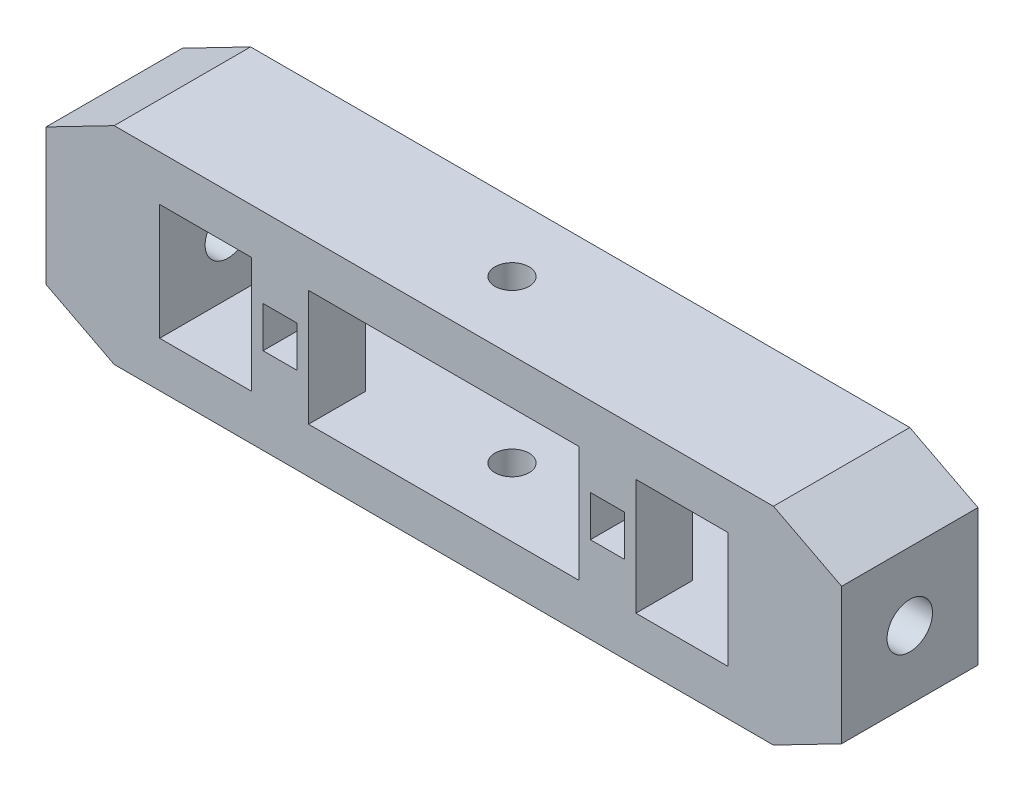
from build123d import *

# Parameters (mm, degrees)
SKETCH1_W                  = 25
SKETCH1_H                  = 6
SKETCH1_R                  = 0.75
BASEFRAME_DEPTH            = 2
SKETCH2_W                  = 29
SKETCH2_H                  = 6
SKETCH2_R                  = 0.75
BOSS_EXTRUDE2_DEPTH        = 2
SKETCH2_3_W                = 2
SKETCH2_3_H                = 6
BOSS_EXTRUDE3_DEPTH        = 7.1
BOSS_EXTRUDE4_DEPTH        = 6
SKETCH4_R                  = 1
SHAFTHOLE_DEPTH            = 36
SLOTBLOCK_START            = -7.1
SKETCH5_W                  = 2.5
SKETCH5_H                  = 2.5
SLOTBLOCK_DEPTH            = 5.1
SKETCH6_W                  = 0.9
SKETCH6_H                  = 0.9
SKETCH6_W_2                = 1.5
SKETCH6_H_2                = 1.5
CLIPENTRANCE_DEPTH         = 2
SKETCH6_3_W                = 0.9
SKETCH6_3_H                = 0.9
CABLEEXIT_DEPTH            = 7
SKETCH7_W                  = 1.5
SKETCH7_H                  = 1.5
CLIPLOCKSLOT_DEPTH         = 0.6
SKETCH8_W                  = 1.5
SKETCH8_H                  = 0.3
CLIPLOCKCLEARANCECUT_DEPTH = 0.5


with BuildPart() as part:
    # Sketch1 → BaseFrame (new body)
    with BuildSketch(Plane(origin=(0, 0, 0), x_dir=(1, 0, 0), z_dir=(0, 1, 0))):
        Rectangle(SKETCH1_W, SKETCH1_H)
        Circle(SKETCH1_R, mode=Mode.SUBTRACT)
    extrude(amount=BASEFRAME_DEPTH)



with BuildPart() as body_2:
    # Sketch2 → Boss-Extrude2 (new body)
    with BuildSketch(Plane(origin=(0, 7.1, 0), x_dir=(1, 0, 0), z_dir=(0, 1, 0))):
        Rectangle(SKETCH2_W, SKETCH2_H)
        Circle(SKETCH2_R, mode=Mode.SUBTRACT)
    extrude(amount=BOSS_EXTRUDE2_DEPTH)


with BuildPart() as part_1:
    add(part.part)

    add(body_2.part)  # Boss-Extrude3 merges body 2
    # Sketch2_3 → Boss-Extrude3 (add)
    with BuildSketch(Plane(origin=(0, 7.1, 0), x_dir=(1, 0, 0), z_dir=(0, 1, 0))):
        with Locations((-13.5, 0)):
            Rectangle(SKETCH2_3_W, SKETCH2_3_H)
        with Locations((13.5, 0)):
            Rectangle(SKETCH2_3_W, SKETCH2_3_H)
    extrude(amount=-BOSS_EXTRUDE3_DEPTH)

    # Sketch3 → Boss-Extrude4 (add)
    with BuildSketch(Plane(origin=(0, 0, -3), x_dir=(-1, 0, 0), z_dir=(0, 0, -1))):
        Polygon((-14.5, 9.1), (-17.5, 7.55), (-17.5, 1.55), (-14.5, 0), align=None)
        Polygon((14.5, 0), (17.5, 1.55), (17.5, 7.55), (14.5, 9.1), align=None)
    extrude(amount=-BOSS_EXTRUDE4_DEPTH)

    # Sketch4 → ShaftHole (cut, through all)
    with BuildSketch(Plane.ZY.offset(17.5)):
        with Locations((0, 4.55)):
            Circle(SKETCH4_R)
    extrude(amount=-SHAFTHOLE_DEPTH, mode=Mode.SUBTRACT)

    # Sketch5 → SlotBlock (add)
    with BuildSketch(Plane(origin=(0, 9.1, 0), x_dir=(1, 0, 0), z_dir=(0, 1, 0)).offset(SLOTBLOCK_START)):
        with Locations((7.2, -1.75)):
            Rectangle(SKETCH5_W, SKETCH5_H)
    slotblock = extrude(amount=SLOTBLOCK_DEPTH)

    # Sketch6 → ClipEntrance (cut)
    with BuildSketch(Plane.XY.offset(3)):
        with Locations((7.2, 4.55)):
            Rectangle(SKETCH6_W, SKETCH6_H)
        with Locations((7.2, 4.55)):
            Rectangle(SKETCH6_W_2, SKETCH6_H_2)
        with Locations((7.2, 4.55)):
            Rectangle(SKETCH6_W, SKETCH6_H, mode=Mode.SUBTRACT)
    clipentrance = extrude(amount=-CLIPENTRANCE_DEPTH, mode=Mode.SUBTRACT)

    # Sketch6_3 → CableExit (cut, through all)
    with BuildSketch(Plane.XY.offset(3)):
        with Locations((7.2, 4.55)):
            Rectangle(SKETCH6_3_W, SKETCH6_3_H)
    cableexit = extrude(amount=-CABLEEXIT_DEPTH, mode=Mode.SUBTRACT)

    # Sketch7 → ClipLockSlot (cut)
    with BuildSketch(Plane.XZ.offset(-5.3)):
        with Locations((7.2, 1.75)):
            Rectangle(SKETCH7_W, SKETCH7_H)
    cliplockslot = extrude(amount=-CLIPLOCKSLOT_DEPTH, mode=Mode.SUBTRACT)

    # Sketch8 → ClipLockClearanceCut (cut)
    with BuildSketch(Plane.XY.offset(3)):
        with Locations((7.2, 5.45)):
            Rectangle(SKETCH8_W, SKETCH8_H)
    cliplockclearancecut = extrude(amount=-CLIPLOCKCLEARANCECUT_DEPTH, mode=Mode.SUBTRACT)

    # Mirror1: SlotBlock, ClipEntrance, CableExit, ClipLockSlot, ClipLockClearanceCut across plane
    add(slotblock.mirror(Plane(origin=(0, 0, 0), x_dir=(0, 0, 1), z_dir=(1, 0, 0))))
    add(clipentrance.mirror(Plane(origin=(0, 0, 0), x_dir=(0, 0, 1), z_dir=(1, 0, 0))), mode=Mode.SUBTRACT)
    add(cableexit.mirror(Plane(origin=(0, 0, 0), x_dir=(0, 0, 1), z_dir=(1, 0, 0))), mode=Mode.SUBTRACT)
    add(cliplockslot.mirror(Plane(origin=(0, 0, 0), x_dir=(0, 0, 1), z_dir=(1, 0, 0))), mode=Mode.SUBTRACT)
    add(cliplockclearancecut.mirror(Plane(origin=(0, 0, 0), x_dir=(0, 0, 1), z_dir=(1, 0, 0))), mode=Mode.SUBTRACT)


solid = part_1.part
